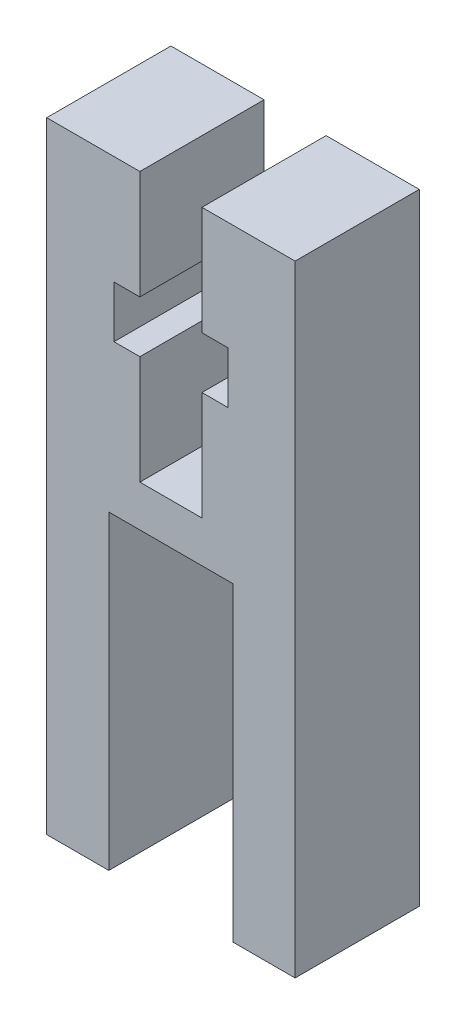
from build123d import *

# Parameters (mm, degrees)
EXTRUDE_1_DEPTH = 6


with BuildPart() as part:
    # Эскиз1 → Бобышка-Вытянуть1 (new body)
    with BuildSketch(Plane.XY):
        Polygon((-1.5, 30), (-1.5, 24.75), (-2.75, 24.75), (-2.75, 22.25), (-1.5, 22.25), (-1.5, 17), (1.5, 17), (1.5, 22.25), (2.75, 22.25), (2.75, 24.75), (1.5, 24.75), (1.5, 30), (6, 30), (6, 0), (3, 0), (3, 15), (-3, 15), (-3, 0), (-6, 0), (-6, 30), align=None)
    extrude(amount=EXTRUDE_1_DEPTH)


solid = part.part
